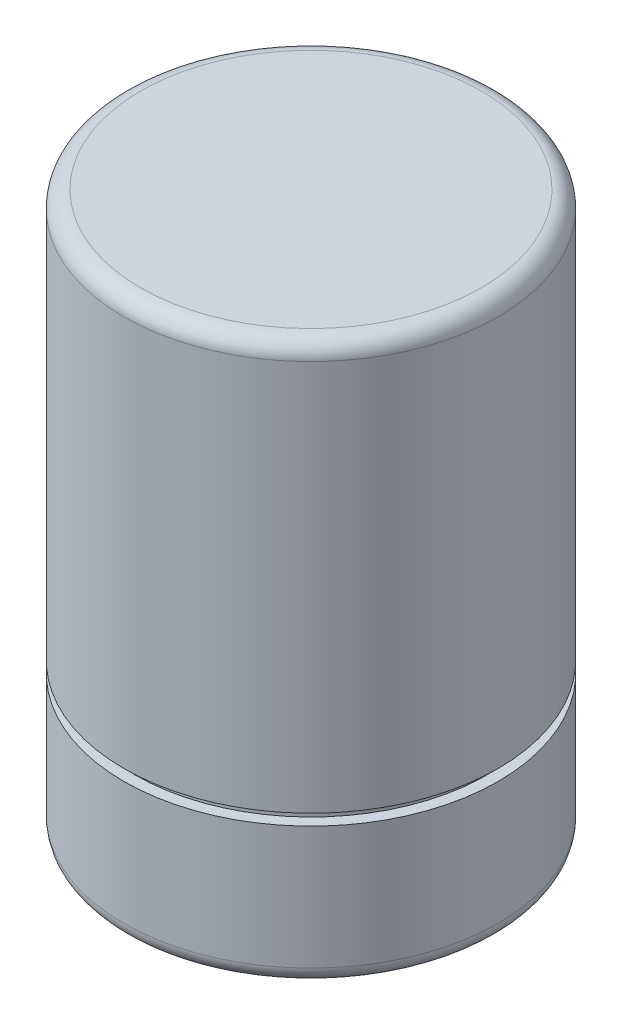
from build123d import *

# Parameters (mm, degrees)
FILLET1_R = 3
FILLET2_R = 3


with BuildPart() as part:
    # Sketch2 → Revolve1 (revolve)
    with BuildSketch(Plane(origin=(0, 0, 0), x_dir=(0, 0, -1), z_dir=(1, 0, 0))):
        Polygon((0, 0), (0, 100), (33.5, 100), (33.5, 27), (31.5, 27), (31.5, 25), (33.5, 25), (33.5, 0), align=None)
    revolve(axis=Axis((0, 0, 0), (0, 1, 0)))

    # Fillet1
    fillet1_edges = [part.edges().sort_by_distance(p)[0] for p in [
        (0, 100, 33.5),
    ]]
    fillet(fillet1_edges, radius=FILLET1_R)

    # Fillet2
    fillet2_edges = [part.edges().sort_by_distance(p)[0] for p in [
        (0, 0, 33.5),
    ]]
    fillet(fillet2_edges, radius=FILLET2_R)


solid = part.part
